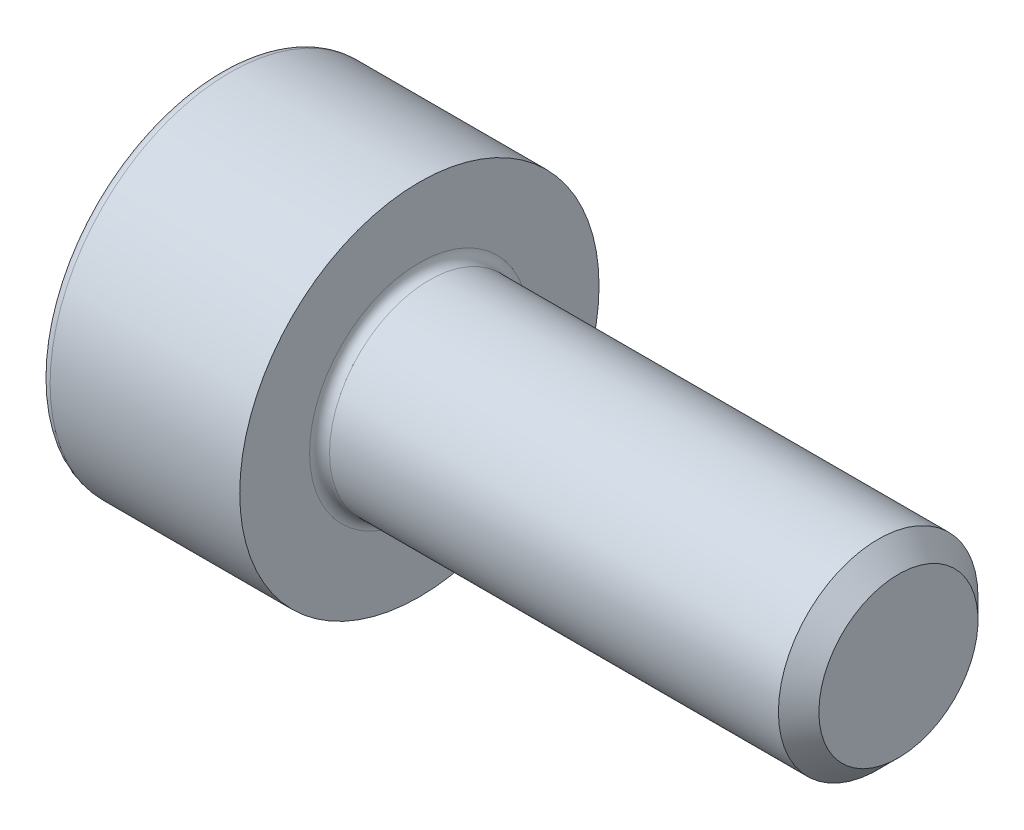
from build123d import *

# Parameters (mm, degrees)
CUT_EXTRUDE1_DEPTH = 1.1


with BuildPart() as part:
    # Sketch1 → Revolve1 (revolve)
    with BuildSketch(Plane.XY):
        with BuildLine():
            Line((5.7465, 1.25), (0.125, 1.25))
            ThreePointArc((0.125, 1.25), (0.036611652, 1.286611652), (0, 1.375))
            Line((0, 1.375), (0, 2.25))
            Line((0, 2.25), (-2.375, 2.25))
            ThreePointArc((-2.375, 2.25), (-2.463388348, 2.213388348), (-2.5, 2.125))
            Line((-2.5, 2.125), (-2.5, 0))
            Line((-2.5, 0), (6, 0))
            Line((6, 0), (6, 0.9965))
            Line((6, 0.9965), (5.7465, 1.25))
        make_face()
    revolve(axis=Axis((-2.5, 0, 0), (1, 0, 0)))

    # Sketch2 → Cut-Extrude1 (cut)
    with BuildSketch(Plane.ZY.offset(2.5)):
        Polygon((1.025, 0.591784026), (0, 1.183568052), (-1.025, 0.591784026), (-1.025, -0.591784026), (0, -1.183568052), (1.025, -0.591784026), align=None)
    extrude(amount=-CUT_EXTRUDE1_DEPTH, mode=Mode.SUBTRACT)


solid = part.part
